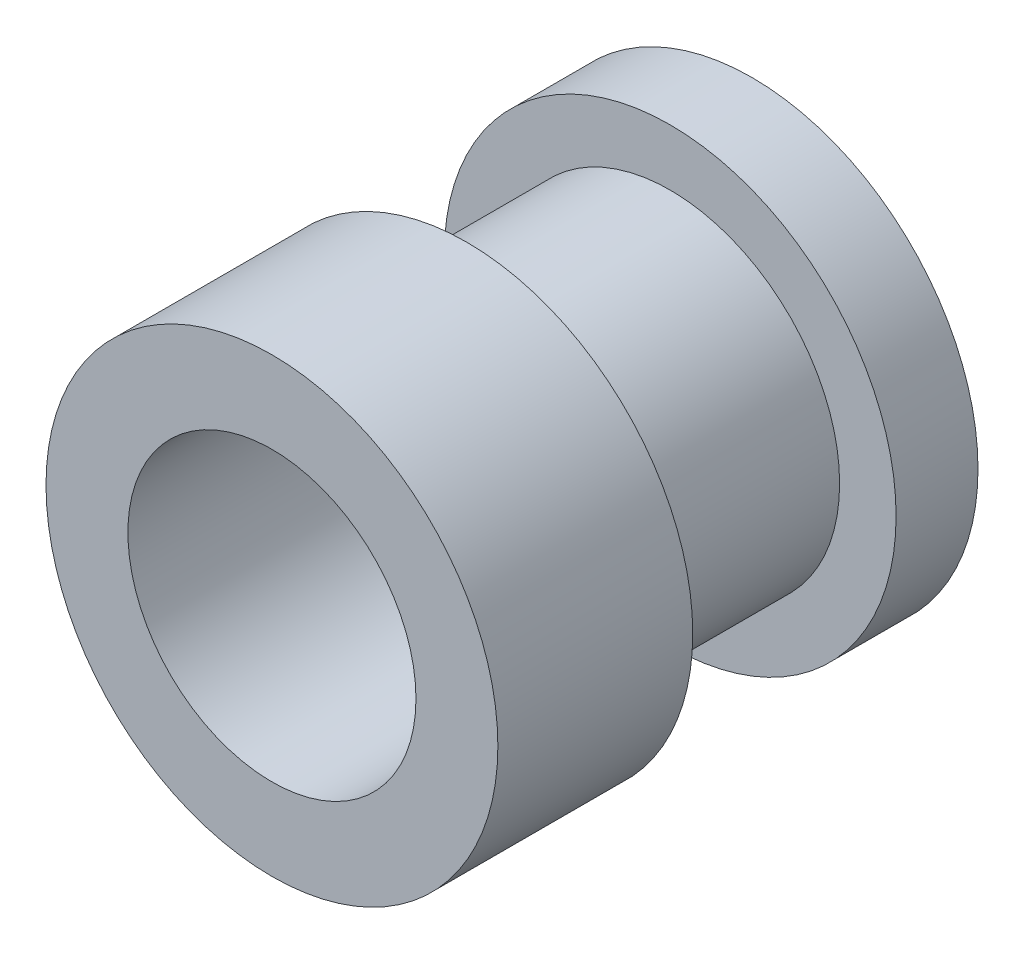
from build123d import *

# Parameters (mm, degrees)
SKETCH1_R           = 3.81
SKETCH1_R_2         = 3.2385
BOSS_EXTRUDE1_DEPTH = 10.795
SKETCH3_R           = 5.08
SKETCH3_R_2         = 3.81
BOSS_EXTRUDE2_DEPTH = 1.8415
SKETCH4_R           = 5.08
SKETCH4_R_2         = 3.81
BOSS_EXTRUDE3_DEPTH = 4.3815


with BuildPart() as part:
    # Sketch1 → Boss-Extrude1 (new body)
    with BuildSketch(Plane.XY):
        Circle(SKETCH1_R)
        Circle(SKETCH1_R_2, mode=Mode.SUBTRACT)
    extrude(amount=BOSS_EXTRUDE1_DEPTH)

    # Sketch3 → Boss-Extrude2 (add)
    with BuildSketch(Plane.XY.offset(1.8415)):
        Circle(SKETCH3_R)
        Circle(SKETCH3_R_2, mode=Mode.SUBTRACT)
    extrude(amount=-BOSS_EXTRUDE2_DEPTH)

    # Sketch4 → Boss-Extrude3 (add)
    with BuildSketch(Plane.XY.offset(6.4135)):
        Circle(SKETCH4_R)
        Circle(SKETCH4_R_2, mode=Mode.SUBTRACT)
    extrude(amount=BOSS_EXTRUDE3_DEPTH)


solid = part.part
